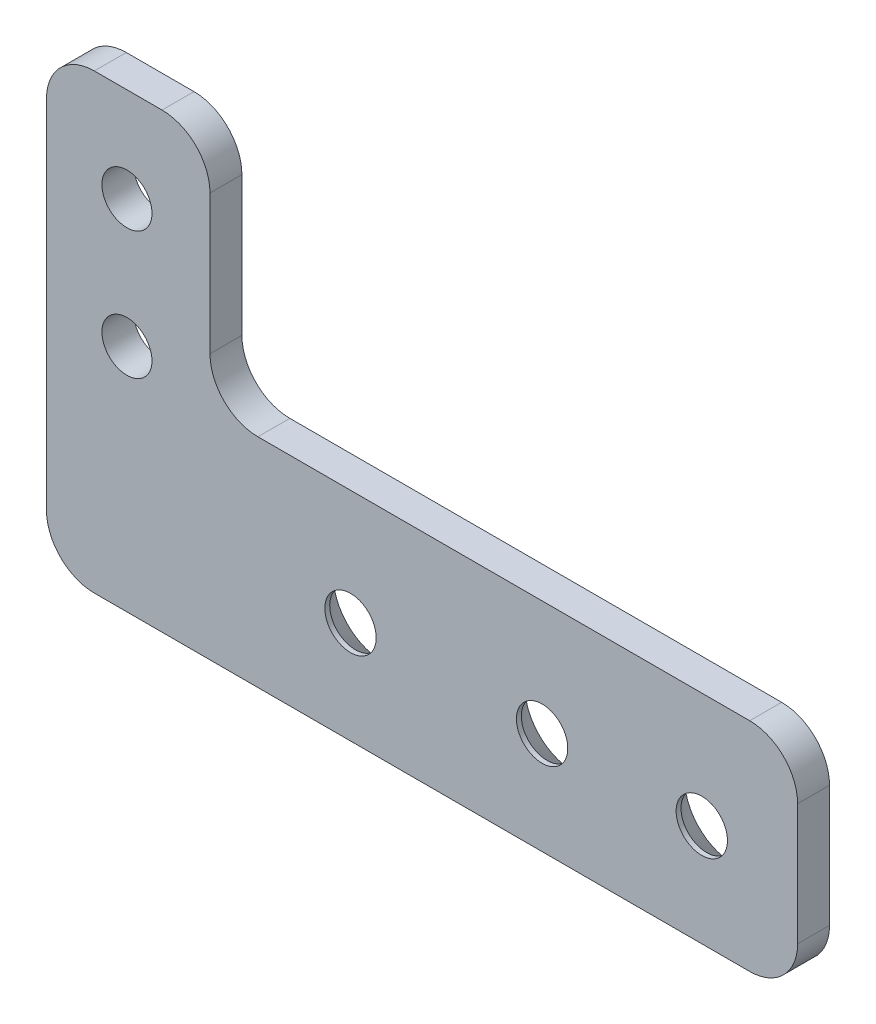
from build123d import *

# Parameters (mm, degrees)
SKETCH1_R                                    = 2.4892
BOSS_EXTRUDE1_DEPTH                          = 3.175
FILLET1_R                                    = 4.7625
CSK_FOR_10_FLAT_HEAD_MACHINE_SCREW3_AT_COUNT = 2
CSK_FOR_10_FLAT_HEAD_MACHINE_SCREW3_AT_PITCH = 15.875
CSK_FOR_10_FLAT_HEAD_MACHINE_SCREW3_2_COUNT  = 2
CSK_FOR_10_FLAT_HEAD_MACHINE_SCREW3_2_PITCH  = 34.925


with BuildPart() as part:
    # Sketch1 → Boss-Extrude1 (new body)
    with BuildSketch(Plane.XY):
        Polygon((-33.401, 23.749), (-33.401, -21.209), (41.275, -21.209), (41.275, 0.381), (-17.145, 0.381), (-17.145, 23.749), align=None)
        with Locations((-25.4, -11.049)):
            Circle(SKETCH1_R, mode=Mode.SUBTRACT)
        with Locations((-25.4, 1.651)):
            Circle(SKETCH1_R, mode=Mode.SUBTRACT)
        with Locations((-25.4, 14.351)):
            Circle(SKETCH1_R, mode=Mode.SUBTRACT)
        with Locations((-25.4, -11.049)):
            Circle(SKETCH1_R)
    extrude(amount=BOSS_EXTRUDE1_DEPTH)

    # Fillet1
    fillet1_edges = [part.edges().sort_by_distance(p)[0] for p in [
        (-33.401, 23.749, 1.5875),
        (-17.145, 23.749, 1.5875),
        (-17.145, 0.381, 1.5875),
        (41.275, 0.381, 1.5875),
        (41.275, -21.209, 1.5875),
        (-33.401, -21.209, 1.5875),
    ]]
    fillet(fillet1_edges, radius=FILLET1_R)

    # Sketch7 → CSK for #10 Flat Head Machine Screw3 (revolve, cut)
    with BuildSketch(Plane(origin=(31.75, -11.049, 0), x_dir=(0, 1, 0), z_dir=(1, 0, 0))):
        Polygon((0, 0), (0, 3.175), (2.5527, 3.175), (2.5527, 2.688180894), (4.8895, 0), align=None)
    csk_for_10_flat_head_machine_screw3 = revolve(axis=Axis((31.75, -11.049, -6.35), (0, 0, 1)), mode=Mode.SUBTRACT)

    # CSK for #10 Flat Head Machine Screw3 at: CSK for #10 Flat Head Machine Screw3 ×2
    with Locations(*[(-i * CSK_FOR_10_FLAT_HEAD_MACHINE_SCREW3_AT_PITCH, 0, 0) for i in range(1, CSK_FOR_10_FLAT_HEAD_MACHINE_SCREW3_AT_COUNT)]):
        add(csk_for_10_flat_head_machine_screw3, mode=Mode.SUBTRACT)

    # CSK for _10 Flat Head Machine Screw3 2: CSK for #10 Flat Head Machine Screw3 ×2
    with Locations(*[(-i * CSK_FOR_10_FLAT_HEAD_MACHINE_SCREW3_2_PITCH, 0, 0) for i in range(1, CSK_FOR_10_FLAT_HEAD_MACHINE_SCREW3_2_COUNT)]):
        add(csk_for_10_flat_head_machine_screw3, mode=Mode.SUBTRACT)


solid = part.part
